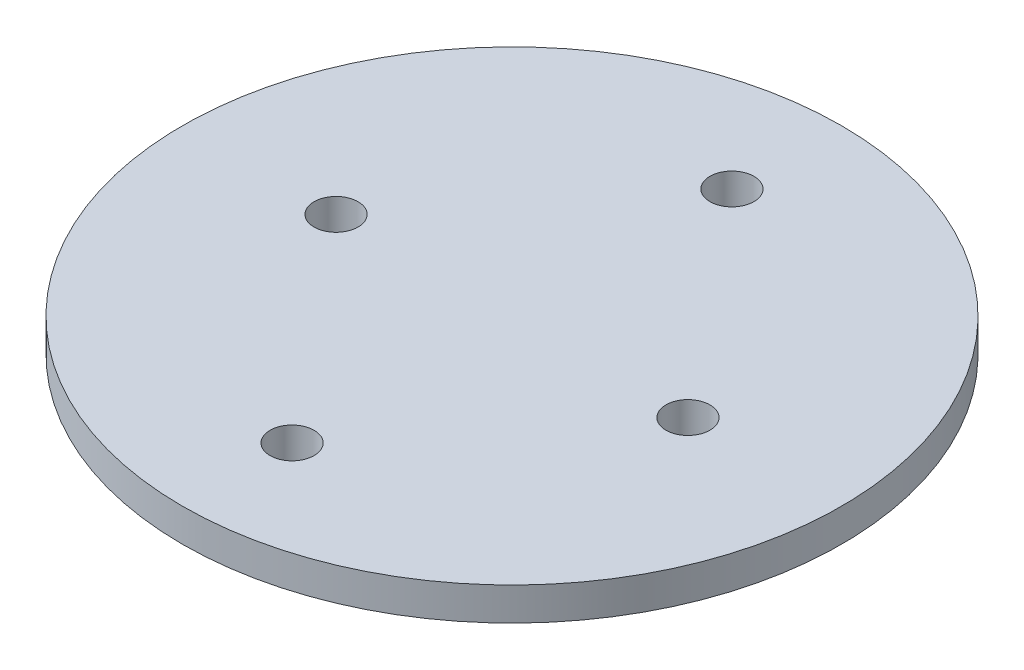
from build123d import *

# Parameters (mm, degrees)
SKETCH1_R           = 47.575
BOSS_EXTRUDE1_DEPTH = 4.7625
SKETCH2_R           = 3.175
CUT_EXTRUDE1_DEPTH  = 5.7625


with BuildPart() as part:
    # Sketch1 → Boss-Extrude1 (new body)
    with BuildSketch(Plane(origin=(0, 0, 0), x_dir=(1, 0, 0), z_dir=(0, 1, 0))):
        Circle(SKETCH1_R)
    extrude(amount=BOSS_EXTRUDE1_DEPTH)

    # Sketch2 → Cut-Extrude1 (cut, through all)
    with BuildSketch(Plane(origin=(0, 4.7625, 0), x_dir=(1, 0, 0), z_dir=(0, 1, 0))):
        with Locations((25.4, 0)):
            Circle(SKETCH2_R)
        with Locations((-25.4, 0)):
            Circle(SKETCH2_R)
        with Locations((0, 31.75)):
            Circle(SKETCH2_R)
        with Locations((0, -31.75)):
            Circle(SKETCH2_R)
    extrude(amount=-CUT_EXTRUDE1_DEPTH, mode=Mode.SUBTRACT)


solid = part.part
